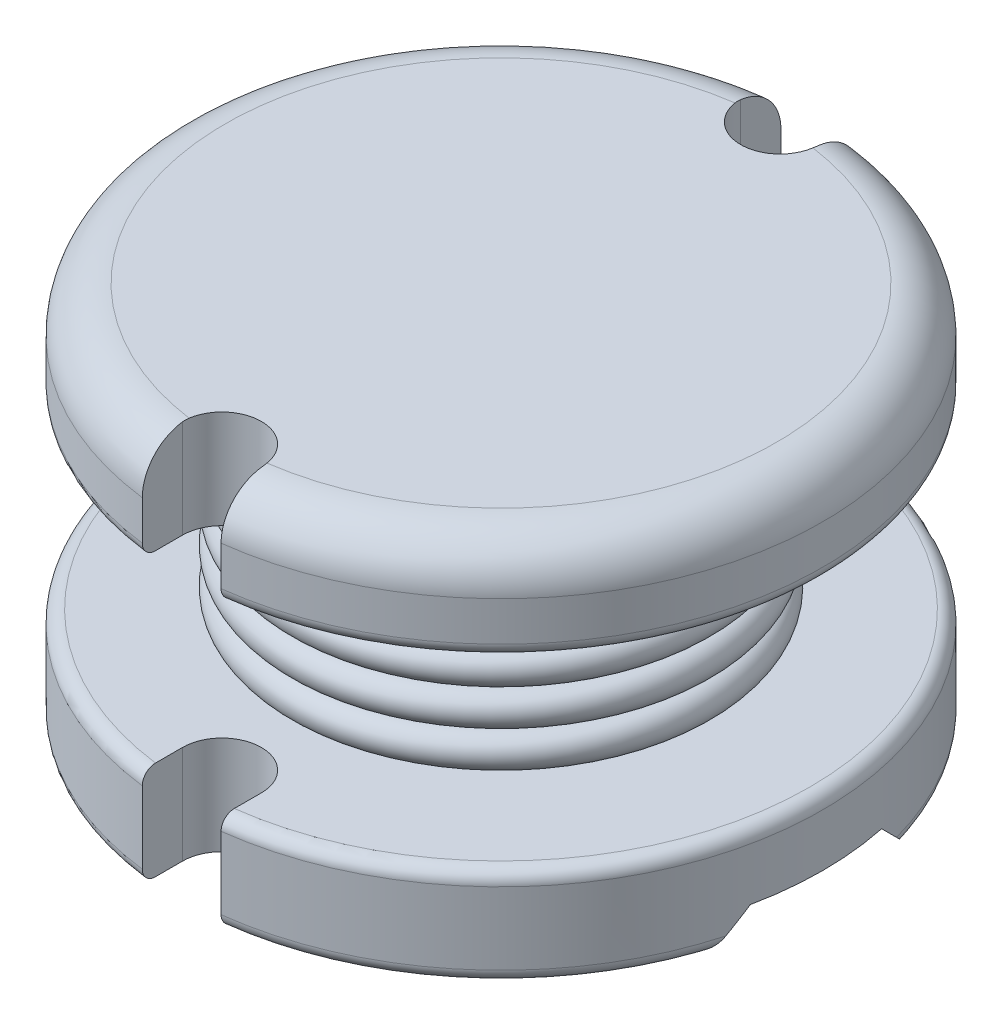
from build123d import *

# Parameters (mm, degrees)
CUT_EXTRUDE1_DEPTH      = 6.8
SKETCH3_R               = 0.25
CUT_EXTRUDE2_DEPTH      = 5.9000001
CUT_EXTRUDE2_DEPTH_BACK = 12


with BuildPart() as part:
    # Sketch1 → Revolve1 (revolve)
    with BuildSketch(Plane.XY):
        with BuildLine():
            Line((0, 0), (-4.7, 0))
            ThreePointArc((-4.7, 0), (-4.841421356, 0.058578644), (-4.9, 0.2))
            Line((-4.9, 0.2), (-4.9, 1.3))
            ThreePointArc((-4.9, 1.3), (-4.841421356, 1.441421356), (-4.7, 1.5))
            Line((-4.7, 1.5), (-2.6, 1.5))
            Line((-2.6, 1.5), (-2.6, 4.3))
            Line((-2.6, 4.3), (-4.7, 4.3))
            ThreePointArc((-4.7, 4.3), (-4.841421356, 4.358578644), (-4.9, 4.5))
            Line((-4.9, 4.5), (-4.9, 5.1))
            ThreePointArc((-4.9, 5.1), (-4.694974747, 5.594974747), (-4.2, 5.8))
            Line((-4.2, 5.8), (0, 5.8))
            Line((0, 5.8), (0, 0))
        make_face()
    revolve(axis=Axis((0, 5.8, 0), (0, -1, 0)))

    # Sketch2 → Cut-Extrude1 (cut, through all)
    with BuildSketch(Plane(origin=(0, 5.8, 0), x_dir=(1, 0, 0), z_dir=(0, 1, 0))):
        with BuildLine():
            Line((-0.6, 6), (0.6, 6))
            Line((0.6, 6), (0.6, 4.25))
            ThreePointArc((0.6, 4.25), (0, 3.65), (-0.6, 4.25))
            Line((-0.6, 4.25), (-0.6, 6))
        make_face()
        with BuildLine():
            Line((-0.6, -6), (0.6, -6))
            Line((0.6, -6), (0.6, -4.25))
            ThreePointArc((0.6, -4.25), (0, -3.65), (-0.6, -4.25))
            Line((-0.6, -4.25), (-0.6, -6))
        make_face()
    extrude(amount=-CUT_EXTRUDE1_DEPTH, mode=Mode.SUBTRACT)

    # Sketch4 → Cut-Extrude2 (cut, two sides)
    with BuildSketch(Plane(origin=(0, 0, 0), x_dir=(0, 0, -1), z_dir=(1, 0, 0))) as cut_extrude2_sk:
        Polygon((-2, -0.5), (-1, 0.5), (1, 0.5), (2, -0.5), align=None)
    extrude(amount=CUT_EXTRUDE2_DEPTH, mode=Mode.SUBTRACT)
    extrude(cut_extrude2_sk.sketch, amount=-CUT_EXTRUDE2_DEPTH_BACK, mode=Mode.SUBTRACT)


with BuildPart() as body_2:
    # Sketch3 → Revolve2 (revolve)
    with BuildSketch(Plane.XY):
        with Locations((-3, 4)):
            Circle(SKETCH3_R)
        with Locations((-3, 3.45)):
            Circle(SKETCH3_R)
        with Locations((-3, 2.9)):
            Circle(SKETCH3_R)
        with Locations((-3, 2.35)):
            Circle(SKETCH3_R)
        with Locations((-3, 1.8)):
            Circle(SKETCH3_R)
    revolve(axis=Axis((0, 0, 0), (0, 1, 0)))


solid = Compound([part.part, body_2.part])
